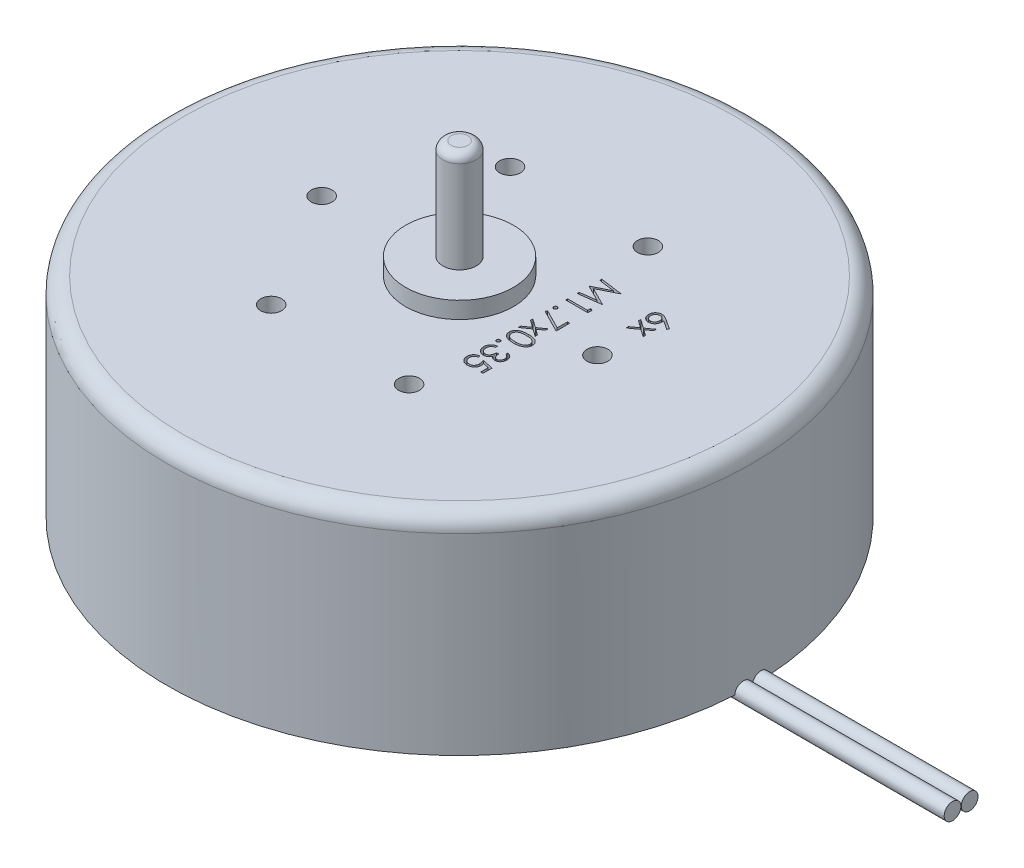
from build123d import *

# Parameters (mm, degrees)
SKIZZE1_R                       = 17.5
AUFSATZ_LINEAR_AUSTRAGEN1_DEPTH = 12.5
SKIZZE2_R                       = 3.225
AUFSATZ_LINEAR_AUSTRAGEN2_DEPTH = 1
SKIZZE3_R                       = 1
AUFSATZ_LINEAR_AUSTRAGEN3_DEPTH = 7
VERRUNDUNG1_R                   = 0.5
SKIZZE4_R                       = 3.05
AUFSATZ_LINEAR_AUSTRAGEN4_DEPTH = 0.5
VERRUNDUNG2_R                   = 1
KREISMUSTER1_COUNT              = 6
SCHNITT_LINEAR_AUSTRAGEN1_DEPTH = 0.5
SKIZZE9_R                       = 0.5
AUFSATZ_LINEAR_AUSTRAGEN8_DEPTH = 30


with BuildPart() as part:
    # Skizze1 → Aufsatz-Linear austragen1 (new body)
    with BuildSketch(Plane(origin=(0, 0, 0), x_dir=(1, 0, 0), z_dir=(0, 1, 0))):
        with Locations(Location((0, 0, 0), (0, 0, 270))):
            Circle(SKIZZE1_R)
    extrude(amount=AUFSATZ_LINEAR_AUSTRAGEN1_DEPTH)

    # Skizze2 → Aufsatz-Linear austragen2 (add)
    with BuildSketch(Plane(origin=(0, 12.5, 0), x_dir=(1, 0, 0), z_dir=(0, 1, 0))):
        with Locations(Location((0, 0, 0), (0, 0, 270))):
            Circle(SKIZZE2_R)
    extrude(amount=AUFSATZ_LINEAR_AUSTRAGEN2_DEPTH)

    # Skizze3 → Aufsatz-Linear austragen3 (add)
    with BuildSketch(Plane(origin=(0, 12.5, 0), x_dir=(1, 0, 0), z_dir=(0, 1, 0))):
        with Locations(Location((0, 0, 0), (0, 0, 270))):
            Circle(SKIZZE3_R)
    extrude(amount=AUFSATZ_LINEAR_AUSTRAGEN3_DEPTH)

    # Verrundung1
    verrundung1_edges = [part.edges().sort_by_distance(p)[0] for p in [
        (0, 19.5, -1),
    ]]
    fillet(verrundung1_edges, radius=VERRUNDUNG1_R)

    # Skizze4 → Aufsatz-Linear austragen4 (add)
    with BuildSketch(Plane.XZ):
        with Locations(Location((0, 0, 0), (0, 0, 90))):
            Circle(SKIZZE4_R)
    extrude(amount=AUFSATZ_LINEAR_AUSTRAGEN4_DEPTH)

    # Verrundung2
    verrundung2_edges = [part.edges().sort_by_distance(p)[0] for p in [
        (0, 12.5, -17.5),
    ]]
    fillet(verrundung2_edges, radius=VERRUNDUNG2_R)

    # Skizze6 → M1.6 Gewindebohrung1 (revolve, cut)
    with BuildSketch(Plane(origin=(8.25, 12.5, 0), x_dir=(0, 0, 1), z_dir=(1, 0, 0))):
        Polygon((0, 0), (0, 5.325537887), (0.625, 4.95), (0.625, 0), align=None)
    m1_6_gewindebohrung1 = revolve(axis=Axis((8.25, 18.85, 0), (0, -1, 0)), mode=Mode.SUBTRACT)

    # Kreismuster1: M1.6 Gewindebohrung1 ×6 about axis
    kreismuster1_axis = Axis((0, 0, 0), (0, 1, 0))
    for i in range(1, KREISMUSTER1_COUNT):
        add(m1_6_gewindebohrung1.rotate(kreismuster1_axis, i * 360 / KREISMUSTER1_COUNT), mode=Mode.SUBTRACT)

    # Skizze8 → Schnitt-Linear austragen1 (cut)
    with BuildSketch(Plane(origin=(0, 12.5, 0), x_dir=(1, 0, 0), z_dir=(0, 1, 0))):
        with BuildLine():
            Line((9.054099544, 3.507717966), (8.982282553, 3.416290432))
            Line((8.982282553, 3.416290432), (8.447762738, 3.76583512))
            add(Edge.make_bspline(
                [(8.447762738, 3.76583512), (8.451472144, 3.742563021), (8.458707759, 3.697168161), (8.459901387, 3.651219146), (8.460483091, 3.628826323)],
                knots=[0, 0, 0, 0, 1.025318673, 2, 2, 2, 2], degree=3))
            add(Edge.make_bspline(
                [(8.460483091, 3.628826323), (8.460121703, 3.615380766), (8.459410323, 3.588913588), (8.453935772, 3.550055064), (8.445308423, 3.512715199), (8.432732303, 3.477048756), (8.416667425, 3.442927718), (8.397413745, 3.410156277), (8.373977074, 3.379350458), (8.34779657, 3.350113554), (8.318799376, 3.323569383), (8.288031609, 3.300068314), (8.255525324, 3.28032783), (8.221296984, 3.264311497), (8.185399354, 3.251874236), (8.14787836, 3.242807478), (8.108708132, 3.237447929), (8.082069059, 3.236720139), (8.068537227, 3.236350445)],
                knots=[0, 0, 0, 0, 1.04369286, 2.054478336, 3.041073146, 4.015093852, 4.984733326, 5.965804835, 6.960378782, 7.985147595, 9.009457201, 10.008161701, 10.986880575, 11.956520048, 12.937015923, 13.931873656, 14.949455224, 16, 16, 16, 16], degree=3))
            add(Edge.make_bspline(
                [(8.068537227, 3.236350445), (8.050035071, 3.237040829), (8.013648672, 3.238398541), (7.960430602, 3.248282108), (7.910137812, 3.265338936), (7.862572661, 3.288158926), (7.81911906, 3.317766069), (7.779848656, 3.352852161), (7.74561873, 3.393748864), (7.716254302, 3.439487736), (7.692924302, 3.488991399), (7.675675956, 3.540897609), (7.665369631, 3.5947627), (7.664020319, 3.631344508), (7.663340997, 3.649761903)],
                knots=[0, 0, 0, 0, 1.031881447, 2.029301251, 3.006342947, 3.987068354, 4.962916383, 5.929513747, 6.915671209, 7.928552063, 8.953527267, 9.960179832, 10.973036711, 12, 12, 12, 12], degree=3))
            add(Edge.make_bspline(
                [(7.663340997, 3.649761903), (7.663918621, 3.667563338), (7.665062793, 3.702824864), (7.675255296, 3.754695542), (7.69177546, 3.804536813), (7.714535327, 3.851998334), (7.743282265, 3.895967418), (7.777894796, 3.935291939), (7.817607941, 3.969835079), (7.862543527, 3.998430688), (7.910518784, 4.021736187), (7.960999175, 4.038173892), (8.012968762, 4.048804199), (8.04834507, 4.049900947), (8.066152161, 4.050453009)],
                knots=[0, 0, 0, 0, 1.011913813, 2.004424092, 2.994488568, 3.992479987, 4.990471406, 5.973328987, 6.963763268, 7.974390938, 8.994854117, 9.989689954, 10.988086187, 12, 12, 12, 12], degree=3))
            add(Edge.make_bspline(
                [(8.066152161, 4.050453009), (8.079771195, 4.049973565), (8.107566285, 4.04899507), (8.149784502, 4.043155519), (8.192813525, 4.032445069), (8.229290364, 4.020854022), (8.259499796, 4.009352204), (8.283355386, 3.998687453), (8.308547655, 3.986762963), (8.334599941, 3.9727858), (8.362256613, 3.957968879), (8.390493461, 3.940661034), (8.420341782, 3.922600031), (8.44021433, 3.909369001), (8.450412812, 3.90257891)],
                knots=[0, 0, 0, 0, 1.17367173, 2.395347028, 3.66355231, 4.98980831, 5.690886799, 6.447442954, 7.240630024, 8.091733897, 8.994365608, 9.943299771, 10.944512865, 12, 12, 12, 12], degree=3))
            Line((8.450412812, 3.90257891), (9.054099544, 3.507717966))
        make_face()
        with BuildLine():
            add(Edge.make_bspline(
                [(8.32479933, 3.653737013), (8.324501352, 3.663814391), (8.323916723, 3.683586122), (8.32061473, 3.712557518), (8.314358358, 3.739903029), (8.306265597, 3.765934986), (8.295246737, 3.790382067), (8.282020982, 3.813523141), (8.266296423, 3.835128583), (8.248248385, 3.854818961), (8.228777033, 3.872899592), (8.207796523, 3.888451886), (8.185947849, 3.901881926), (8.163025659, 3.912797665), (8.139044656, 3.92129862), (8.114113558, 3.927447565), (8.088065611, 3.930869686), (8.070401835, 3.931439003), (8.061382029, 3.931729718)],
                knots=[0, 0, 0, 0, 1.129474985, 2.216020618, 3.260639938, 4.268601163, 5.26556745, 6.258792394, 7.250684778, 8.252748164, 9.247500881, 10.223461414, 11.174097059, 12.117127289, 13.062595836, 14.020469732, 14.98917545, 16, 16, 16, 16], degree=3))
            add(Edge.make_bspline(
                [(8.061382029, 3.931729718), (8.05244324, 3.931492358), (8.034915605, 3.931026931), (8.009080167, 3.926820325), (7.98424081, 3.920348818), (7.960379367, 3.910876247), (7.937625998, 3.898994872), (7.915819079, 3.884373531), (7.894943559, 3.867259798), (7.875525844, 3.847365422), (7.857715444, 3.825911267), (7.841857031, 3.803222077), (7.828540204, 3.779369995), (7.818012202, 3.754218918), (7.809389518, 3.728120982), (7.803317464, 3.700877094), (7.799885565, 3.672463316), (7.799315459, 3.653216067), (7.799024757, 3.643401727)],
                knots=[0, 0, 0, 0, 0.989642335, 1.94054129, 2.892446913, 3.828371744, 4.778262963, 5.730973156, 6.732161388, 7.763274768, 8.805796303, 9.818398792, 10.825975928, 11.825728216, 12.834635236, 13.867465554, 14.912602056, 16, 16, 16, 16], degree=3))
            add(Edge.make_bspline(
                [(7.799024757, 3.643401727), (7.799315437, 3.63358737), (7.799885498, 3.61434009), (7.803317721, 3.585926541), (7.809388577, 3.558681807), (7.818015614, 3.532586942), (7.828527547, 3.50742453), (7.841940476, 3.483551569), (7.857619024, 3.460645757), (7.875556498, 3.439205676), (7.89483384, 3.419228148), (7.916008092, 3.402515256), (7.937452679, 3.387431993), (7.960470038, 3.376006949), (7.984226446, 3.366428883), (8.009084015, 3.359990027), (8.034914598, 3.355774716), (8.0524429, 3.355310485), (8.061382029, 3.355073735)],
                knots=[0, 0, 0, 0, 1.087205562, 2.132157158, 3.164804748, 4.173533273, 5.173108684, 6.180507559, 7.20098426, 8.243321352, 9.274252308, 10.269075238, 11.227079059, 12.172305571, 13.108064818, 14.05980203, 15.010532752, 16, 16, 16, 16], degree=3))
            add(Edge.make_bspline(
                [(8.061382029, 3.355073735), (8.070414649, 3.355279309), (8.088142743, 3.355682782), (8.11409009, 3.360334664), (8.139247387, 3.366617805), (8.163047925, 3.376771937), (8.186149884, 3.388866337), (8.207892994, 3.404273808), (8.228893241, 3.421938851), (8.248377522, 3.442396684), (8.266199432, 3.464652975), (8.281930254, 3.488320919), (8.295206759, 3.513081178), (8.306284119, 3.538909833), (8.314278124, 3.566102516), (8.320572651, 3.594220297), (8.323922284, 3.623622777), (8.324503258, 3.643571079), (8.32479933, 3.653737013)],
                knots=[0, 0, 0, 0, 0.978265087, 1.920016216, 2.851775529, 3.783928695, 4.718195979, 5.674835085, 6.667117013, 7.690134047, 8.732874136, 9.755756613, 10.767227014, 11.776017537, 12.797239016, 13.836276431, 14.897336092, 16, 16, 16, 16], degree=3))
        make_face(mode=Mode.SUBTRACT)
        Polygon((8.664008732, 3.100666684), (8.664008732, 2.959417769), (8.315259066, 2.710575872), (8.664008732, 2.461733975), (8.664008732, 2.32048506), (8.216411326, 2.639818911), (7.697261937, 2.26960365), (7.697261937, 2.410852565), (8.117298579, 2.710575872), (7.697261937, 3.010299179), (7.697261937, 3.151548094), (8.216411326, 2.781067826), align=None)
        Polygon((4.441519416, 4.067413479), (5.764436082, 3.892773638), (5.764436082, 3.875813168), (4.678965997, 3.32963303), (5.764436082, 2.784777929), (5.764436082, 2.767552451), (4.441519416, 2.591852581), (4.441519416, 2.711105887), (5.393425799, 2.837779398), (4.441519416, 3.315322633), (4.441519416, 3.342088375), (5.395545858, 3.821486663), (4.441519416, 3.947895166), align=None)
        Polygon((5.764436082, 2.158035557), (5.764436082, 1.913433778), (4.441519416, 1.913433778), (4.441519416, 2.032157069), (5.628752322, 2.032157069), (5.628752322, 2.23568271), align=None)
        with BuildLine():
            add(Edge.make_bspline(
                [(4.645045057, 1.209574269), (4.644621763, 1.202202334), (4.643796823, 1.187835483), (4.637733929, 1.167031847), (4.627504082, 1.148021079), (4.613448167, 1.131191955), (4.596667317, 1.117204797), (4.577704841, 1.106857241), (4.556840893, 1.10051644), (4.542266796, 1.099732662), (4.534802001, 1.099331214)],
                knots=[0, 0, 0, 0, 1.020591893, 1.988988293, 2.974634352, 3.991697318, 5.008760285, 5.983632262, 6.967224335, 8, 8, 8, 8], degree=3))
            add(Edge.make_bspline(
                [(4.534802001, 1.099331214), (4.5275167, 1.099748699), (4.513125391, 1.100573395), (4.492419312, 1.106844076), (4.473444228, 1.117285813), (4.456435246, 1.131096486), (4.442349241, 1.148025174), (4.432210612, 1.167077808), (4.42572348, 1.18778561), (4.4249534, 1.202193942), (4.424558945, 1.209574269)],
                knots=[0, 0, 0, 0, 1.009852967, 1.994853009, 2.971120474, 3.99910934, 5.017628188, 6.004685157, 6.977947174, 8, 8, 8, 8], degree=3))
            add(Edge.make_bspline(
                [(4.424558945, 1.209574269), (4.424968209, 1.216949283), (4.425771899, 1.231431941), (4.43208107, 1.252217327), (4.442446441, 1.271154632), (4.45640921, 1.288086617), (4.47353234, 1.301782582), (4.492290128, 1.312705357), (4.513185205, 1.318474259), (4.527528481, 1.319365416), (4.534802001, 1.319817325)],
                knots=[0, 0, 0, 0, 1.021616397, 2.006195831, 2.982046417, 4.000130345, 5.027680246, 6.00943514, 6.990578253, 8, 8, 8, 8], degree=3))
            add(Edge.make_bspline(
                [(4.534802001, 1.319817325), (4.542254594, 1.319380228), (4.556780097, 1.318528303), (4.577833972, 1.312691978), (4.596580045, 1.301865095), (4.613473941, 1.287990921), (4.627407194, 1.271158793), (4.637861509, 1.252262002), (4.643749121, 1.231382927), (4.644607297, 1.216941106), (4.645045057, 1.209574269)],
                knots=[0, 0, 0, 0, 1.032329927, 2.012066096, 2.992413168, 4.009037178, 5.025661188, 6.000112418, 6.979848586, 8, 8, 8, 8], degree=3))
        make_face()
        Polygon((5.764436082, 0.827963692), (5.764436082, 0.013861128), (4.407598475, 0.709240402), (4.46404504, 0.811798244), (5.628752322, 0.214736696), (5.628752322, 0.827963692), align=None)
        Polygon((5.40826621, -0.104862162), (5.40826621, -0.246111077), (5.059516544, -0.494952974), (5.40826621, -0.743794871), (5.40826621, -0.885043786), (4.960668805, -0.565709935), (4.441519416, -0.935925196), (4.441519416, -0.794676281), (4.861556057, -0.494952974), (4.441519416, -0.195229667), (4.441519416, -0.053980752), (4.960668805, -0.42446102), align=None)
        with BuildLine():
            add(Edge.make_bspline(
                [(5.102447734, -0.986806607), (5.123651211, -0.98693059), (5.164839271, -0.987171429), (5.224856085, -0.989850683), (5.281159527, -0.994301482), (5.333752293, -1.000401025), (5.382647963, -1.007823711), (5.427715852, -1.017732552), (5.469164606, -1.029001045), (5.507129196, -1.04206117), (5.542121751, -1.056797202), (5.574787054, -1.072837835), (5.605083636, -1.090810903), (5.633466631, -1.109719903), (5.659619272, -1.130255821), (5.683492032, -1.152202052), (5.705099326, -1.175776294), (5.724698317, -1.200512304), (5.741771537, -1.226566405), (5.757155643, -1.253135436), (5.76978232, -1.280688229), (5.780157396, -1.308973495), (5.788470681, -1.337908976), (5.794227615, -1.367614233), (5.797835665, -1.39809644), (5.798181588, -1.418669995), (5.798357022, -1.429103866)],
                knots=[0, 0, 0, 0, 1.646377244, 3.198111528, 4.663803227, 6.031090796, 7.308794487, 8.502186765, 9.612154809, 10.642545331, 11.617106989, 12.558866172, 13.465886467, 14.35053239, 15.20542558, 16.045215227, 16.865619885, 17.686225247, 18.492864914, 19.282407821, 20.068097601, 20.842842034, 21.620163247, 22.403093475, 23.190129512, 24, 24, 24, 24], degree=3))
            add(Edge.make_bspline(
                [(5.798357022, -1.429103866), (5.79817264, -1.439625014), (5.797805961, -1.460548267), (5.794281733, -1.49148198), (5.788434017, -1.521701056), (5.78014841, -1.551076662), (5.769869092, -1.579850095), (5.756984973, -1.607796297), (5.741987306, -1.635088854), (5.724364591, -1.661294052), (5.704716528, -1.686699576), (5.682505638, -1.710681396), (5.657956191, -1.733241693), (5.631330843, -1.754663609), (5.602118921, -1.774339385), (5.570828499, -1.793076963), (5.536912368, -1.809848536), (5.500936418, -1.826001225), (5.461905213, -1.839943628), (5.420038771, -1.852517477), (5.374842576, -1.862677087), (5.326553757, -1.871139699), (5.274994976, -1.877695656), (5.220276755, -1.882470494), (5.162363096, -1.884992762), (5.122767123, -1.885467765), (5.102447734, -1.885711521)],
                knots=[0, 0, 0, 0, 0.810914788, 1.612654377, 2.396697861, 3.181598691, 3.963628158, 4.749916497, 5.551656086, 6.361998678, 7.18212741, 8.025565596, 8.878627764, 9.750805457, 10.657531673, 11.591944965, 12.560506719, 13.57287815, 14.630710178, 15.753379473, 16.941251878, 18.199788006, 19.531962791, 20.947069417, 22.433333509, 24, 24, 24, 24], degree=3))
            add(Edge.make_bspline(
                [(5.102447734, -1.885711521), (5.082217047, -1.885464933), (5.042798378, -1.884984467), (4.985144256, -1.882502078), (4.930720096, -1.877589249), (4.879374401, -1.871512855), (4.831412028, -1.862857116), (4.786376913, -1.853017065), (4.7446577, -1.840786939), (4.705832343, -1.827034572), (4.670032652, -1.811232379), (4.63640971, -1.794312577), (4.605144819, -1.775690015), (4.575933322, -1.755896897), (4.549077064, -1.734657064), (4.52450967, -1.712001237), (4.502247346, -1.687912171), (4.482330829, -1.662449208), (4.464913254, -1.635831765), (4.449344744, -1.608630307), (4.436711863, -1.580301916), (4.426045677, -1.551476168), (4.417741009, -1.521881073), (4.412054859, -1.491545661), (4.408055893, -1.460569278), (4.407751476, -1.439628654), (4.407598475, -1.429103866)],
                knots=[0, 0, 0, 0, 1.56130642, 3.042141888, 4.451772327, 5.777565838, 7.030558081, 8.211376819, 9.333164717, 10.383253789, 11.387583522, 12.350962576, 13.286244149, 14.193812918, 15.072134482, 15.925989337, 16.770211267, 17.600669898, 18.417446232, 19.22325363, 20.01647746, 20.807971184, 21.593601364, 22.38506573, 23.188331689, 24, 24, 24, 24], degree=3))
            add(Edge.make_bspline(
                [(4.407598475, -1.429103866), (4.407775598, -1.418670419), (4.408124849, -1.3980977), (4.411708515, -1.36760937), (4.417552266, -1.337950442), (4.425488052, -1.309061626), (4.435573964, -1.2808838), (4.448402871, -1.253692994), (4.463282407, -1.227130111), (4.480210664, -1.201316358), (4.499610006, -1.17674373), (4.521065102, -1.15327144), (4.545114089, -1.131492155), (4.571372027, -1.111213618), (4.599616117, -1.091970387), (4.630124584, -1.074173442), (4.663095942, -1.058164097), (4.698281667, -1.043097818), (4.736525278, -1.029816921), (4.778195102, -1.018174133), (4.823521647, -1.00846824), (4.872370353, -1.000662711), (4.924777779, -0.994227838), (4.980836199, -0.989871758), (5.040497249, -0.987169295), (5.081420742, -0.986929709), (5.102447734, -0.986806607)],
                knots=[0, 0, 0, 0, 0.810940842, 1.599017053, 2.38298203, 3.159479784, 3.926441347, 4.70693857, 5.494146311, 6.292334103, 7.104379492, 7.925868426, 8.762126819, 9.623561095, 10.503686106, 11.41783325, 12.366995289, 13.351843594, 14.392337808, 15.512229747, 16.713911458, 17.994391108, 19.357476964, 20.818259213, 22.365182633, 24, 24, 24, 24], degree=3))
        make_face()
        with BuildLine():
            add(Edge.make_bspline(
                [(5.102977749, -1.105529897), (5.085307854, -1.105575045), (5.051014057, -1.105662669), (5.001180444, -1.107951769), (4.954700587, -1.11107016), (4.911515471, -1.115092318), (4.871771267, -1.121065453), (4.835194641, -1.127758208), (4.801979103, -1.135902835), (4.77189692, -1.145539472), (4.744436912, -1.156515125), (4.718886624, -1.168500704), (4.694936281, -1.181369476), (4.672829138, -1.195796734), (4.652345135, -1.211455238), (4.633543138, -1.228370698), (4.616505183, -1.246513366), (4.596287998, -1.271628766), (4.575149109, -1.304622485), (4.556968051, -1.346406556), (4.545468474, -1.389360295), (4.544010137, -1.418522977), (4.543282236, -1.433078976)],
                knots=[0, 0, 0, 0, 1.459116078, 2.831857795, 4.118796693, 5.306371758, 6.412361096, 7.436813035, 8.376339383, 9.234574298, 10.043323891, 10.816788787, 11.564361537, 12.286735248, 12.994408768, 13.691741332, 14.372975427, 15.047457468, 16.352811911, 17.594285292, 18.799233213, 20, 20, 20, 20], degree=3))
            add(Edge.make_bspline(
                [(4.543282236, -1.433078976), (4.543886159, -1.447728453), (4.545092758, -1.476997161), (4.556733948, -1.519759042), (4.574298327, -1.561272269), (4.595067176, -1.593805413), (4.614846039, -1.618556256), (4.631709314, -1.636289761), (4.650591442, -1.65256619), (4.670964093, -1.668003522), (4.69321649, -1.682162161), (4.71724163, -1.695037216), (4.74310623, -1.706785981), (4.761162054, -1.713479579), (4.770393531, -1.716901842)],
                knots=[0, 0, 0, 0, 1.353760809, 2.704726607, 4.075137775, 5.516104923, 6.260822281, 7.007110065, 7.778089737, 8.566572457, 9.372053459, 10.217411131, 11.088608312, 12, 12, 12, 12], degree=3))
            add(Edge.make_bspline(
                [(4.770393531, -1.716901842), (4.782197629, -1.720890159), (4.80616501, -1.728988153), (4.843344128, -1.739424747), (4.882352316, -1.74764399), (4.922956452, -1.755038476), (4.965455982, -1.760085613), (5.009719407, -1.764148031), (5.0557801, -1.76654088), (5.087074636, -1.766837497), (5.102977749, -1.766988231)],
                knots=[0, 0, 0, 0, 0.884706709, 1.796334032, 2.740027952, 3.714592787, 4.726048262, 5.777819803, 6.87074269, 8, 8, 8, 8], degree=3))
            add(Edge.make_bspline(
                [(5.102977749, -1.766988231), (5.11888052, -1.766821988), (5.149993588, -1.76649674), (5.195512035, -1.764359838), (5.238820299, -1.760926012), (5.279957666, -1.756278405), (5.318850917, -1.749898224), (5.355555709, -1.74223626), (5.390062145, -1.733253488), (5.422459215, -1.72294998), (5.452630475, -1.711338069), (5.480641614, -1.698510389), (5.50664113, -1.684821516), (5.530554395, -1.669950562), (5.552489348, -1.654077325), (5.572005987, -1.636782028), (5.589709248, -1.618750919), (5.609916825, -1.593495611), (5.630520949, -1.560432413), (5.649482411, -1.51929135), (5.66037126, -1.476477743), (5.661906481, -1.447534801), (5.662673262, -1.433078976)],
                knots=[0, 0, 0, 0, 1.313668642, 2.570134578, 3.763346207, 4.902004944, 5.98888779, 7.017888835, 7.998425394, 8.933058446, 9.82474457, 10.667209444, 11.476765193, 12.250262638, 12.991704352, 13.7104269, 14.401925311, 15.076585796, 16.378385137, 17.609787933, 18.806186071, 20, 20, 20, 20], degree=3))
            add(Edge.make_bspline(
                [(5.662673262, -1.433078976), (5.661906412, -1.418446679), (5.660371317, -1.38915543), (5.649510965, -1.345906135), (5.630697484, -1.304472004), (5.609783771, -1.271674069), (5.590066979, -1.246450626), (5.572921182, -1.228639353), (5.554062305, -1.211987668), (5.533665026, -1.196316119), (5.511546734, -1.181902749), (5.487599873, -1.16902871), (5.462047211, -1.157050011), (5.43459345, -1.146050794), (5.404465917, -1.136503463), (5.371418014, -1.127969911), (5.334807224, -1.121281215), (5.294951906, -1.115444376), (5.251713702, -1.110994118), (5.205126688, -1.107959774), (5.155206896, -1.105658527), (5.120736158, -1.105573633), (5.102977749, -1.105529897)],
                knots=[0, 0, 0, 0, 1.207964612, 2.418129846, 3.655795183, 4.951004962, 5.620895151, 6.296795572, 6.989224116, 7.696855977, 8.419187164, 9.166715907, 9.940135271, 10.748837255, 11.607021648, 12.548275234, 13.5654991, 14.678641405, 15.874140913, 17.15372626, 18.533675393, 20, 20, 20, 20], degree=3))
        make_face(mode=Mode.SUBTRACT)
        with BuildLine():
            add(Edge.make_bspline(
                [(4.645045057, -2.216440688), (4.644621763, -2.223812623), (4.643796823, -2.238179475), (4.637733929, -2.25898311), (4.627504082, -2.277993878), (4.613448167, -2.294823002), (4.596667317, -2.30881016), (4.577704841, -2.319157717), (4.556840893, -2.325498517), (4.542266796, -2.326282295), (4.534802001, -2.326683743)],
                knots=[0, 0, 0, 0, 1.020591893, 1.988988293, 2.974634352, 3.991697318, 5.008760285, 5.983632262, 6.967224335, 8, 8, 8, 8], degree=3))
            add(Edge.make_bspline(
                [(4.534802001, -2.326683743), (4.5275167, -2.326266258), (4.513125391, -2.325441562), (4.492419312, -2.319170881), (4.473444228, -2.308729144), (4.456435246, -2.294918472), (4.442349241, -2.277989783), (4.432210612, -2.258937149), (4.42572348, -2.238229348), (4.4249534, -2.223821015), (4.424558945, -2.216440688)],
                knots=[0, 0, 0, 0, 1.009852967, 1.994853009, 2.971120474, 3.99910934, 5.017628188, 6.004685157, 6.977947174, 8, 8, 8, 8], degree=3))
            add(Edge.make_bspline(
                [(4.424558945, -2.216440688), (4.424968209, -2.209065675), (4.425771899, -2.194583017), (4.43208107, -2.17379763), (4.442446441, -2.154860325), (4.45640921, -2.13792834), (4.47353234, -2.124232375), (4.492290128, -2.113309601), (4.513185205, -2.107540698), (4.527528481, -2.106649541), (4.534802001, -2.106197632)],
                knots=[0, 0, 0, 0, 1.021616397, 2.006195831, 2.982046417, 4.000130345, 5.027680246, 6.00943514, 6.990578253, 8, 8, 8, 8], degree=3))
            add(Edge.make_bspline(
                [(4.534802001, -2.106197632), (4.542254594, -2.106634729), (4.556780097, -2.107486654), (4.577833972, -2.113322979), (4.596580045, -2.124149862), (4.613473941, -2.138024036), (4.627407194, -2.154856164), (4.637861509, -2.173752955), (4.643749121, -2.194632031), (4.644607297, -2.209073852), (4.645045057, -2.216440688)],
                knots=[0, 0, 0, 0, 1.032329927, 2.012066096, 2.992413168, 4.009037178, 5.025661188, 6.000112418, 6.979848586, 8, 8, 8, 8], degree=3))
        make_face()
        with BuildLine():
            Line((5.459147621, -2.682853615), (5.459147621, -2.564130325))
            add(Edge.make_bspline(
                [(5.459147621, -2.564130325), (5.472464661, -2.567346732), (5.498498385, -2.573634546), (5.535693986, -2.586749402), (5.57089246, -2.601036621), (5.603434726, -2.618192622), (5.633974788, -2.636905752), (5.661819963, -2.65834559), (5.687678435, -2.681522985), (5.710626593, -2.707159201), (5.731406866, -2.734044142), (5.749124521, -2.762556632), (5.764366091, -2.792123024), (5.776922548, -2.822948166), (5.7863816, -2.855123832), (5.79324444, -2.888359136), (5.7977012, -2.922741173), (5.798136161, -2.946080292), (5.798357022, -2.957931239)],
                knots=[0, 0, 0, 0, 1.162005537, 2.271625781, 3.343758855, 4.383309926, 5.390229558, 6.379919256, 7.361854164, 8.333198761, 9.295911338, 10.242430842, 11.177959212, 12.116337295, 13.062827104, 14.020064771, 14.994644689, 16, 16, 16, 16], degree=3))
            add(Edge.make_bspline(
                [(5.798357022, -2.957931239), (5.797835706, -2.975198228), (5.796804445, -3.009355563), (5.787387381, -3.059536833), (5.77248562, -3.107927923), (5.751895848, -3.153999156), (5.726500644, -3.196793028), (5.696275877, -3.234868908), (5.661804712, -3.267710697), (5.623730201, -3.295263036), (5.583038982, -3.316836027), (5.541159161, -3.332743674), (5.498190082, -3.342428059), (5.469177658, -3.34368315), (5.454642496, -3.344311949)],
                knots=[0, 0, 0, 0, 1.083050992, 2.142477498, 3.193116406, 4.255571735, 5.30263384, 6.308962982, 7.297363603, 8.282367274, 9.249857812, 10.179914175, 11.08814088, 12, 12, 12, 12], degree=3))
            add(Edge.make_bspline(
                [(5.454642496, -3.344311949), (5.440654809, -3.343872139), (5.413283075, -3.343011499), (5.373322866, -3.335703819), (5.335660714, -3.323405886), (5.300138072, -3.306370589), (5.266980171, -3.284318872), (5.236112409, -3.257606276), (5.207397876, -3.226044258), (5.190948552, -3.202126326), (5.182479952, -3.189812666)],
                knots=[0, 0, 0, 0, 1.024540389, 2.004866551, 2.965041327, 3.920577974, 4.882998113, 5.874504559, 6.905732034, 8, 8, 8, 8], degree=3))
            add(Edge.make_bspline(
                [(5.182479952, -3.189812666), (5.175684632, -3.203885383), (5.162221136, -3.231767505), (5.135817323, -3.269773211), (5.105331144, -3.304274075), (5.08154032, -3.323514469), (5.069586823, -3.33318164)],
                knots=[0, 0, 0, 0, 1.015518401, 2.012035669, 3.001164323, 4, 4, 4, 4], degree=3))
            add(Edge.make_bspline(
                [(5.069586823, -3.33318164), (5.060872471, -3.339549858), (5.04358647, -3.352182009), (5.015777883, -3.367730203), (4.987753129, -3.381996719), (4.95841031, -3.392496462), (4.928691971, -3.401557325), (4.897961722, -3.40751907), (4.866511528, -3.411346272), (4.845225154, -3.41188369), (4.834525308, -3.412153829)],
                knots=[0, 0, 0, 0, 1.02516404, 2.033540309, 3.025129118, 4.011046665, 4.991655828, 5.976607087, 6.982917762, 8, 8, 8, 8], degree=3))
            add(Edge.make_bspline(
                [(4.834525308, -3.412153829), (4.816001537, -3.411474052), (4.779041168, -3.410117697), (4.724422114, -3.398043322), (4.671123412, -3.379216803), (4.619934775, -3.35294902), (4.57214098, -3.320448871), (4.529572534, -3.281569103), (4.492735385, -3.237254879), (4.462056324, -3.187796224), (4.4375144, -3.134235227), (4.420484982, -3.076941983), (4.40939256, -3.016749603), (4.408203164, -2.975471796), (4.407598475, -2.954486144)],
                knots=[0, 0, 0, 0, 0.95570045, 1.906903359, 2.87519758, 3.868912786, 4.869932978, 5.851730567, 6.836639976, 7.83677598, 8.849487602, 9.869908895, 10.917060885, 12, 12, 12, 12], degree=3))
            add(Edge.make_bspline(
                [(4.407598475, -2.954486144), (4.407926639, -2.940342539), (4.408572357, -2.912512642), (4.41298659, -2.871599177), (4.421048824, -2.832546034), (4.43189799, -2.795300413), (4.445653202, -2.759829223), (4.462782591, -2.726240707), (4.482933069, -2.694328218), (4.506342491, -2.6643929), (4.532529188, -2.636438322), (4.56195804, -2.611207382), (4.594085035, -2.588279424), (4.629283333, -2.568268368), (4.667098058, -2.550262734), (4.708013413, -2.535453265), (4.751663624, -2.522418541), (4.782082293, -2.516358273), (4.797689287, -2.513248914)],
                knots=[0, 0, 0, 0, 1.048658725, 2.063410685, 3.046034179, 4.001477787, 4.936774919, 5.862367409, 6.792675028, 7.730719943, 8.675894397, 9.627829632, 10.600096036, 11.597688215, 12.626045268, 13.701542398, 14.82072376, 16, 16, 16, 16], degree=3))
            Line((4.797689287, -2.513248914), (4.797689287, -2.631972205))
            add(Edge.make_bspline(
                [(4.797689287, -2.631972205), (4.787503202, -2.635065294), (4.767690381, -2.641081622), (4.739175742, -2.651322621), (4.713035644, -2.662990093), (4.689078333, -2.675506608), (4.667067872, -2.688652032), (4.647586272, -2.703360948), (4.629777848, -2.718543928), (4.619744616, -2.729988803), (4.614834219, -2.735590077)],
                knots=[0, 0, 0, 0, 1.198163088, 2.33053128, 3.407730985, 4.417276592, 5.372219308, 6.28897303, 7.162600585, 8, 8, 8, 8], degree=3))
            add(Edge.make_bspline(
                [(4.614834219, -2.735590077), (4.609123629, -2.742997116), (4.597720075, -2.757788331), (4.583167376, -2.781891204), (4.570557703, -2.807240134), (4.560925473, -2.834384371), (4.552769631, -2.862738168), (4.547432411, -2.892759821), (4.543770513, -2.924184466), (4.543447369, -2.945641329), (4.543282236, -2.956606203)],
                knots=[0, 0, 0, 0, 0.946170439, 1.889420265, 2.845303464, 3.807233317, 4.801018734, 5.828864929, 6.890507805, 8, 8, 8, 8], degree=3))
            add(Edge.make_bspline(
                [(4.543282236, -2.956606203), (4.543514655, -2.968986414), (4.54396913, -2.99319485), (4.548160773, -3.02851622), (4.554238786, -3.062129484), (4.56374598, -3.093691618), (4.575151429, -3.123632105), (4.590083256, -3.151282588), (4.606946341, -3.177455956), (4.626561351, -3.20138545), (4.647763054, -3.222959059), (4.670256172, -3.241601041), (4.69334327, -3.25774713), (4.717562926, -3.27072589), (4.742677563, -3.280992699), (4.768781186, -3.287977695), (4.795653986, -3.292835585), (4.813921223, -3.293231136), (4.823129992, -3.293430538)],
                knots=[0, 0, 0, 0, 1.216990249, 2.379719373, 3.493992396, 4.571561497, 5.616923107, 6.638958652, 7.655775068, 8.674704564, 9.676001865, 10.625896028, 11.54399481, 12.441854662, 13.322657739, 14.20572845, 15.095482574, 16, 16, 16, 16], degree=3))
            add(Edge.make_bspline(
                [(4.823129992, -3.293430538), (4.835456316, -3.292852131), (4.860047629, -3.291698195), (4.896226385, -3.282887953), (4.931085452, -3.268397375), (4.964025077, -3.248108093), (4.994568637, -3.223421732), (5.021714375, -3.194577257), (5.044338782, -3.16150391), (5.059912575, -3.130867928), (5.070291853, -3.103666114), (5.077569609, -3.080433604), (5.083387318, -3.054401092), (5.089014794, -3.025881095), (5.093732514, -2.994753327), (5.097683788, -2.960989747), (5.100840462, -2.924576769), (5.102250918, -2.899369147), (5.102977749, -2.886379256)],
                knots=[0, 0, 0, 0, 1.070481957, 2.135637345, 3.216366529, 4.339485895, 5.485746587, 6.620975969, 7.768829582, 8.956804399, 9.598399438, 10.297751078, 11.070570279, 11.915248466, 12.824061284, 13.805856426, 14.869322739, 16, 16, 16, 16], degree=3))
            Line((5.102977749, -2.886379256), (5.23866151, -2.886379256))
            add(Edge.make_bspline(
                [(5.23866151, -2.886379256), (5.238940459, -2.902745614), (5.239486852, -2.934803287), (5.246049619, -2.981638752), (5.255230066, -3.026478174), (5.268967384, -3.068298043), (5.285456086, -3.106291079), (5.304048302, -3.139434054), (5.325112449, -3.166941491), (5.34837208, -3.188882115), (5.373609616, -3.204985754), (5.399638379, -3.21707313), (5.42706397, -3.22415924), (5.445770006, -3.225110508), (5.45517251, -3.225588658)],
                knots=[0, 0, 0, 0, 1.321708579, 2.588902423, 3.815526512, 5.016621128, 6.138757764, 7.158873101, 8.079948563, 8.928590313, 9.728601868, 10.489025425, 11.240515403, 12, 12, 12, 12], degree=3))
            add(Edge.make_bspline(
                [(5.45517251, -3.225588658), (5.46208108, -3.225432039), (5.47582535, -3.225120452), (5.495905117, -3.221190261), (5.515372159, -3.215285744), (5.534138143, -3.207163092), (5.552094146, -3.19631088), (5.569262194, -3.18328461), (5.585930006, -3.168077996), (5.601300175, -3.150293612), (5.61579818, -3.13104012), (5.628331166, -3.110136357), (5.638954116, -3.08804338), (5.647730938, -3.064740873), (5.654328981, -3.040135487), (5.659067554, -3.014347704), (5.662029911, -2.987326997), (5.662456438, -2.968892453), (5.662673262, -2.959521283)],
                knots=[0, 0, 0, 0, 0.884317272, 1.759307272, 2.611736065, 3.488921043, 4.37244062, 5.294096728, 6.247679003, 7.258495569, 8.302441962, 9.333537773, 10.376747089, 11.440883505, 12.520330301, 13.637364711, 14.798958396, 16, 16, 16, 16], degree=3))
            add(Edge.make_bspline(
                [(5.662673262, -2.959521283), (5.66214838, -2.944457804), (5.661123164, -2.915035325), (5.652111979, -2.872627694), (5.637834685, -2.833244756), (5.620594895, -2.803242903), (5.60363556, -2.781050883), (5.589045444, -2.764888632), (5.57250324, -2.749306566), (5.553555216, -2.734916141), (5.532852916, -2.72085505), (5.51028232, -2.707257557), (5.48552164, -2.694560413), (5.468109215, -2.686831453), (5.459147621, -2.682853615)],
                knots=[0, 0, 0, 0, 1.4727372, 2.876598283, 4.222346151, 5.558423782, 6.24313385, 6.953189256, 7.68715613, 8.463578749, 9.278833271, 10.135787152, 11.040551781, 12, 12, 12, 12], degree=3))
        make_face()
        with BuildLine():
            Line((5.764436082, -4.361940154), (5.628752322, -4.361940154))
            Line((5.628752322, -4.361940154), (5.628752322, -3.911957682))
            Line((5.628752322, -3.911957682), (5.280797677, -3.840670706))
            add(Edge.make_bspline(
                [(5.280797677, -3.840670706), (5.284664477, -3.854676944), (5.292155788, -3.881811815), (5.300473446, -3.92186212), (5.305487468, -3.959883578), (5.3061721, -3.984556114), (5.30650339, -3.996495025)],
                knots=[0, 0, 0, 0, 1.100273476, 2.13160584, 3.095893838, 4, 4, 4, 4], degree=3))
            add(Edge.make_bspline(
                [(5.30650339, -3.996495025), (5.306183563, -4.011267697), (5.305554702, -4.040314461), (5.299518913, -4.08281443), (5.290012305, -4.123381078), (5.276753259, -4.161945093), (5.259689043, -4.19858954), (5.238649223, -4.233109778), (5.213779327, -4.265701447), (5.18531931, -4.295933696), (5.153958261, -4.323317853), (5.120349013, -4.347489934), (5.084460996, -4.367593304), (5.046452904, -4.384132648), (5.006388509, -4.397255021), (4.963971257, -4.406012951), (4.91957756, -4.411838156), (4.889224498, -4.412489447), (4.873746395, -4.412821564)],
                knots=[0, 0, 0, 0, 1.052772836, 2.070014431, 3.053871312, 4.019926262, 4.972333346, 5.930471369, 6.896690565, 7.89035727, 8.885779078, 9.861050232, 10.836829716, 11.812751485, 12.812646763, 13.836748493, 14.896881366, 16, 16, 16, 16], degree=3))
            add(Edge.make_bspline(
                [(4.873746395, -4.412821564), (4.862965661, -4.412570215), (4.841549885, -4.412070914), (4.809745588, -4.409530952), (4.778613626, -4.404643406), (4.748154467, -4.398072005), (4.718408832, -4.389576614), (4.68938754, -4.379180642), (4.661001229, -4.366926354), (4.633248041, -4.353090973), (4.606983562, -4.337086001), (4.581802361, -4.32022663), (4.558631158, -4.301551089), (4.53662405, -4.281963552), (4.516645292, -4.260680797), (4.497839904, -4.238363405), (4.481024756, -4.214487642), (4.465558615, -4.189480974), (4.451710834, -4.16335917), (4.44015931, -4.13585736), (4.4300343, -4.10757928), (4.421800588, -4.078272891), (4.415412418, -4.047994969), (4.411062161, -4.016641248), (4.40789697, -3.984369057), (4.407698652, -3.962493726), (4.407598475, -3.951443776)],
                knots=[0, 0, 0, 0, 1.05623316, 2.098192244, 3.122504159, 4.140841222, 5.148757784, 6.150489607, 7.158294732, 8.176043417, 9.185147859, 10.169157858, 11.142149047, 12.097904048, 13.0527185, 13.998867679, 14.954465986, 15.910220987, 16.877849176, 17.847023716, 18.829548819, 19.818454515, 20.826519638, 21.858115382, 22.918063636, 24, 24, 24, 24], degree=3))
            add(Edge.make_bspline(
                [(4.407598475, -3.951443776), (4.407859619, -3.938262182), (4.408373387, -3.912328954), (4.41374731, -3.874334343), (4.421445576, -3.837779364), (4.433021018, -3.802953319), (4.447546512, -3.769562379), (4.465787994, -3.738051042), (4.486748288, -3.707799937), (4.511150593, -3.679631254), (4.538072686, -3.653540364), (4.566975184, -3.629826013), (4.597973005, -3.609028668), (4.630802256, -3.591063458), (4.665519424, -3.575761528), (4.702228395, -3.563734743), (4.740744502, -3.554029341), (4.767260813, -3.549923171), (4.780728817, -3.54783759)],
                knots=[0, 0, 0, 0, 1.046825758, 2.059506013, 3.044032586, 4.011925612, 4.970610144, 5.93275819, 6.900651216, 7.891265644, 8.889116719, 9.876966323, 10.858259055, 11.851035124, 12.847502422, 13.86866322, 14.9174643, 16, 16, 16, 16], degree=3))
            Line((4.780728817, -3.54783759), (4.780728817, -3.66656088))
            add(Edge.make_bspline(
                [(4.780728817, -3.66656088), (4.768112109, -3.669480252), (4.743862096, -3.675091448), (4.709810613, -3.68744011), (4.679351897, -3.702445549), (4.652457193, -3.72069456), (4.62888112, -3.742023226), (4.60769008, -3.766186771), (4.588825576, -3.793529438), (4.572999873, -3.823901505), (4.559522788, -3.855962852), (4.55054392, -3.889513673), (4.544231718, -3.923646845), (4.543599787, -3.946732978), (4.543282236, -3.958333967)],
                knots=[0, 0, 0, 0, 1.136389429, 2.184203582, 3.172920998, 4.111012962, 5.028380909, 5.957351669, 6.927793475, 7.937618031, 8.960409703, 9.974842029, 10.982339866, 12, 12, 12, 12], degree=3))
            add(Edge.make_bspline(
                [(4.543282236, -3.958333967), (4.543592471, -3.969657546), (4.544203325, -3.991953765), (4.548904975, -4.024766402), (4.556146081, -4.056445673), (4.566982604, -4.086678989), (4.580153078, -4.115995405), (4.597054312, -4.143653348), (4.616504973, -4.170452947), (4.638789176, -4.1955612), (4.663346173, -4.218557063), (4.689606974, -4.238875597), (4.717621377, -4.255800204), (4.746904384, -4.270062799), (4.777776934, -4.280893064), (4.810094343, -4.288619268), (4.843936433, -4.293156138), (4.867019179, -4.293780245), (4.878781535, -4.294098273)],
                knots=[0, 0, 0, 0, 1.027316725, 2.022795036, 3.002884548, 3.971462791, 4.93288096, 5.914575861, 6.907176829, 7.935150275, 8.956128384, 9.956726525, 10.942570165, 11.921478529, 12.907843606, 13.90538589, 14.932640048, 16, 16, 16, 16], degree=3))
            add(Edge.make_bspline(
                [(4.878781535, -4.294098273), (4.889399895, -4.293889472), (4.910195734, -4.293480538), (4.940486432, -4.288936282), (4.96935523, -4.282570485), (4.996543966, -4.272796616), (5.022450778, -4.26072017), (5.046521166, -4.245398873), (5.06937354, -4.227885053), (5.090079532, -4.207371525), (5.109319186, -4.185002394), (5.12569642, -4.160258398), (5.139480477, -4.133703928), (5.151374199, -4.105646325), (5.159916864, -4.075421659), (5.166330286, -4.043627529), (5.170040269, -4.00992087), (5.170555029, -3.986875399), (5.170819629, -3.97502943)],
                knots=[0, 0, 0, 0, 1.045726679, 2.048034203, 3.01323695, 3.95502507, 4.889743367, 5.8246644, 6.761650845, 7.722168973, 8.692072792, 9.66525385, 10.638902184, 11.638179751, 12.663148338, 13.728659964, 14.832472288, 16, 16, 16, 16], degree=3))
            add(Edge.make_bspline(
                [(5.170819629, -3.97502943), (5.170607632, -3.964686292), (5.170173639, -3.943512282), (5.166758211, -3.910957279), (5.161503904, -3.876895728), (5.15393077, -3.841195391), (5.144448685, -3.803954242), (5.132606749, -3.765110348), (5.118966333, -3.72466277), (5.108386361, -3.697438655), (5.102977749, -3.68352135)],
                knots=[0, 0, 0, 0, 0.824638674, 1.688163388, 2.607705698, 3.571998603, 4.597075385, 5.671199175, 6.809488238, 8, 8, 8, 8], degree=3))
            Line((5.102977749, -3.68352135), (5.764436082, -3.819205111))
            Line((5.764436082, -3.819205111), (5.764436082, -4.361940154))
        make_face()
    extrude(amount=-SCHNITT_LINEAR_AUSTRAGEN1_DEPTH, mode=Mode.SUBTRACT)

    # Skizze9 → Aufsatz-Linear austragen8 (add)
    with BuildSketch(Plane(origin=(0, 0, 0), x_dir=(0, 0, -1), z_dir=(1, 0, 0))):
        with Locations((0.523217371, 0)):
            Circle(SKIZZE9_R)
        with Locations((-0.5, 0)):
            Circle(SKIZZE9_R)
    extrude(amount=AUFSATZ_LINEAR_AUSTRAGEN8_DEPTH)


solid = part.part
